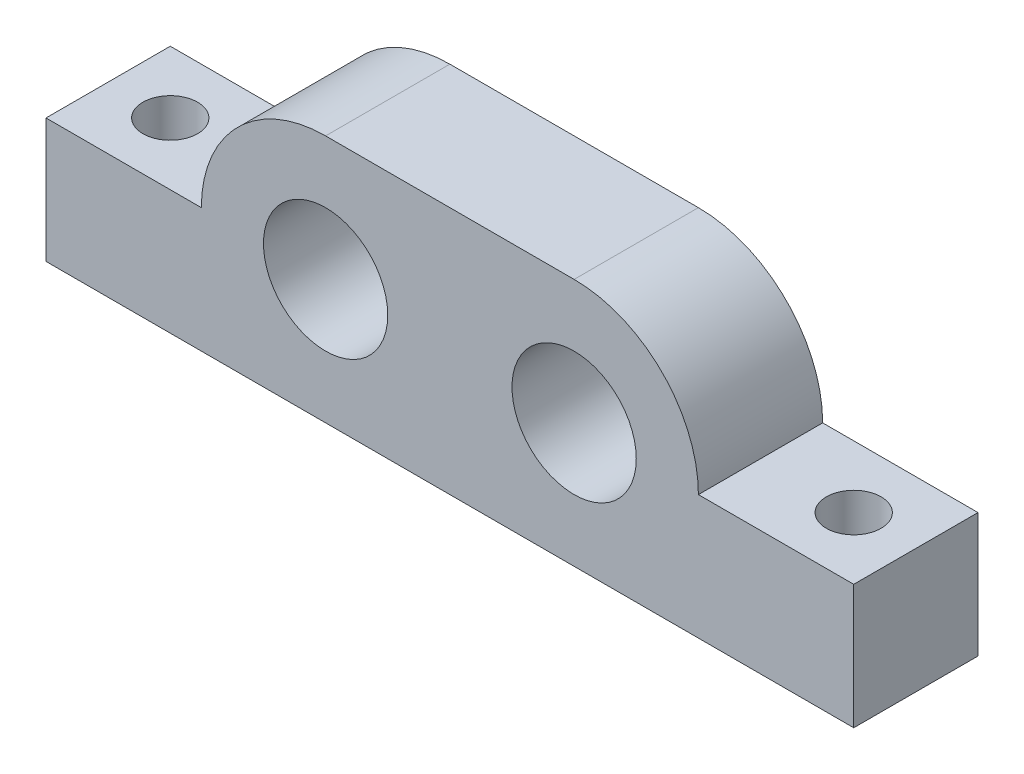
from build123d import *

# Parameters (mm, degrees)
SKETCH1_R           = 3.175
BOSS_EXTRUDE1_DEPTH = 6.35
CUT_EXTRUDE1_REACH  = 8.35
SKETCH2_R           = 1.397


with BuildPart() as part:
    # Sketch1 → Boss-Extrude1 (new body)
    with BuildSketch(Plane.XY):
        with BuildLine():
            Line((0, 0), (41.275, 0))
            Line((41.275, 0), (41.275, 6.35))
            Line((41.275, 6.35), (33.3375, 6.35))
            ThreePointArc((33.3375, 6.35), (31.477628061, 10.840128061), (26.9875, 12.7))
            Line((26.9875, 12.7), (14.2875, 12.7))
            ThreePointArc((14.2875, 12.7), (9.797371939, 10.840128061), (7.9375, 6.35))
            Line((7.9375, 6.35), (0, 6.35))
            Line((0, 6.35), (0, 0))
        make_face()
        with Locations((14.2875, 6.35)):
            Circle(SKETCH1_R, mode=Mode.SUBTRACT)
        with Locations((26.9875, 6.35)):
            Circle(SKETCH1_R, mode=Mode.SUBTRACT)
    extrude(amount=BOSS_EXTRUDE1_DEPTH)

    # Sketch2 → Cut-Extrude1 (cut, up to next)
    with BuildSketch(Plane(origin=(0, 6.35, 0), x_dir=(1, 0, 0), z_dir=(0, 1, 0)), mode=Mode.PRIVATE) as cut_extrude1_sk1:
        with Locations((38.1, -3.175)):
            Circle(SKETCH2_R)
    cut_extrude1_tool1 = extrude(cut_extrude1_sk1.sketch, amount=-CUT_EXTRUDE1_REACH, mode=Mode.PRIVATE) & part.part
    add(cut_extrude1_tool1.solids().sort_by_distance((38.1, 6.35, 3.175))[0], mode=Mode.SUBTRACT)
    # Sketch2 → Cut-Extrude1 (cut, up to next)
    with BuildSketch(Plane(origin=(0, 6.35, 0), x_dir=(1, 0, 0), z_dir=(0, 1, 0)), mode=Mode.PRIVATE) as cut_extrude1_sk2:
        with Locations((3.175, -3.175)):
            Circle(SKETCH2_R)
    cut_extrude1_tool2 = extrude(cut_extrude1_sk2.sketch, amount=-CUT_EXTRUDE1_REACH, mode=Mode.PRIVATE) & part.part
    add(cut_extrude1_tool2.solids().sort_by_distance((3.175, 6.35, 3.175))[0], mode=Mode.SUBTRACT)


solid = part.part
